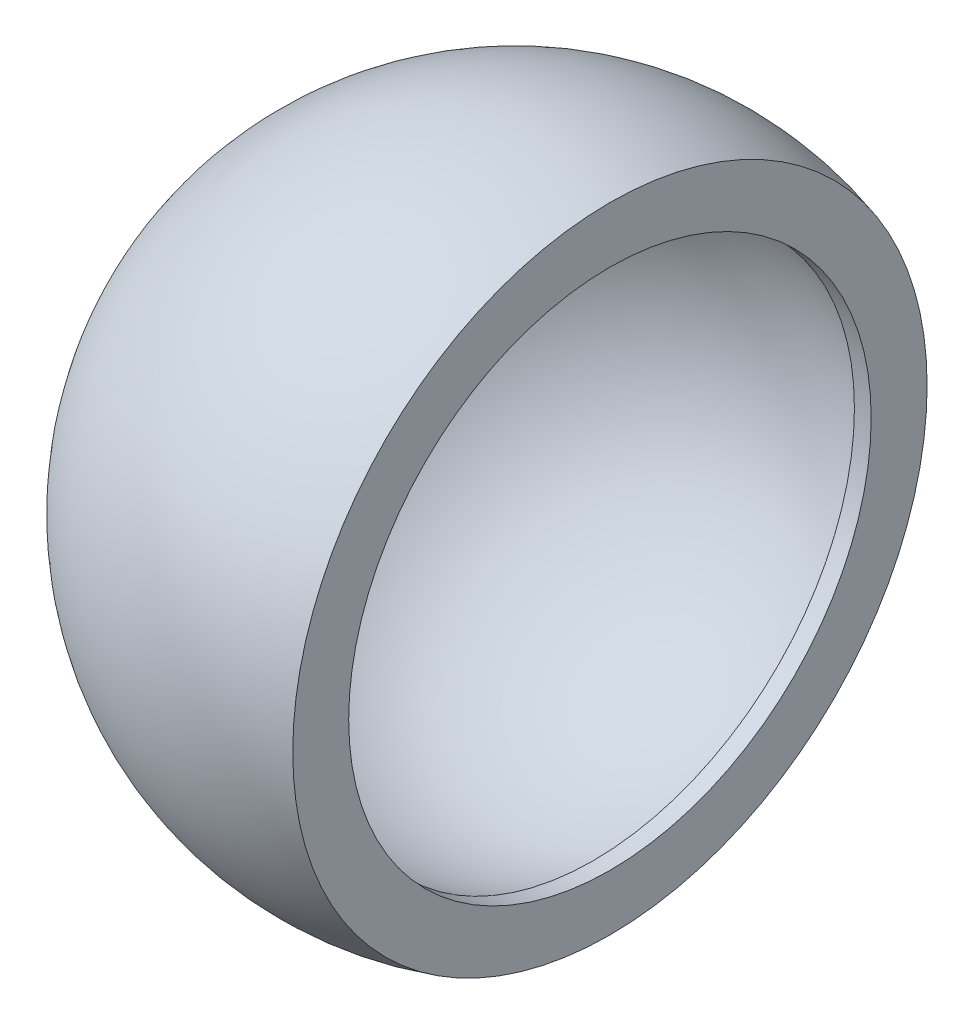
from build123d import *


with BuildPart() as part:
    # Croquis1 → Revolución1 (revolve)
    with BuildSketch(Plane(origin=(0, 0, 0), x_dir=(1, 0, 0), z_dir=(0, 1, 0))):
        with BuildLine():
            Line((-10, 0), (-12.14103606, 0))
            ThreePointArc((-12.14103606, 0), (-7.249832975, 9.738823258), (3.482783518, 11.630777084))
            Line((3.482783518, 11.630777084), (3.482783518, 9.579723696))
            Line((3.482783518, 9.579723696), (2.868604871, 9.579723696))
            ThreePointArc((2.868604871, 9.579723696), (-5.971346217, 8.021410372), (-10, 0))
        make_face()
    revolve(axis=Axis((-10, 0, 0), (-1, 0, 0)))


solid = part.part
